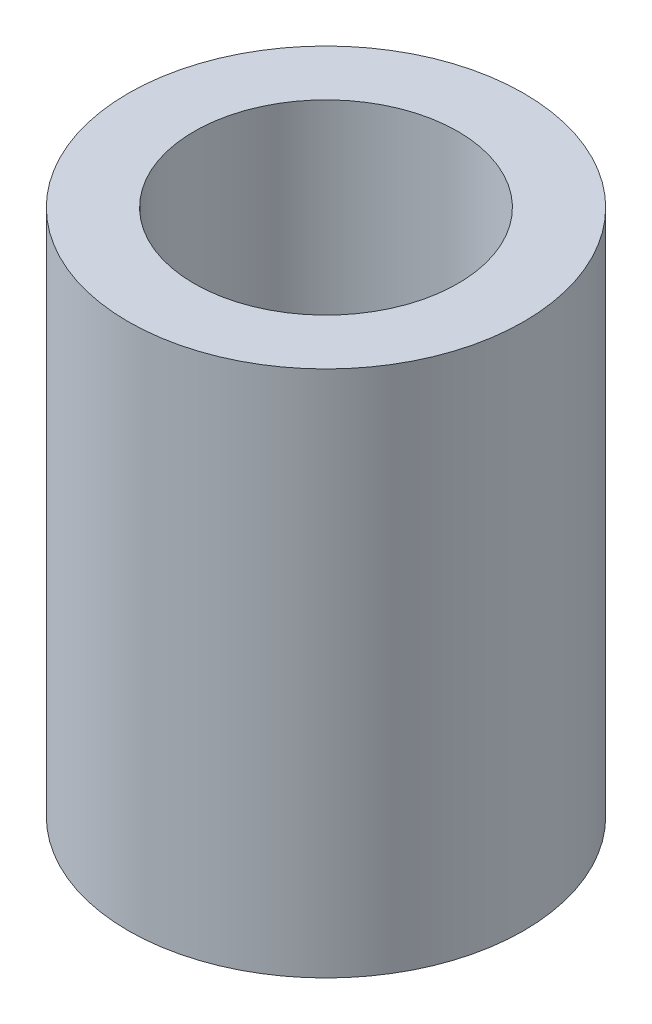
from build123d import *

# Parameters (mm, degrees)
SKETCH1_R           = 2.25
SKETCH1_R_2         = 1.5
BOSS_EXTRUDE1_DEPTH = 6


with BuildPart() as part:
    # Sketch1 → Boss-Extrude1 (new body)
    with BuildSketch(Plane(origin=(0, 0, 0), x_dir=(1, 0, 0), z_dir=(0, 1, 0))):
        Circle(SKETCH1_R)
        Circle(SKETCH1_R_2, mode=Mode.SUBTRACT)
    extrude(amount=BOSS_EXTRUDE1_DEPTH)


solid = part.part
